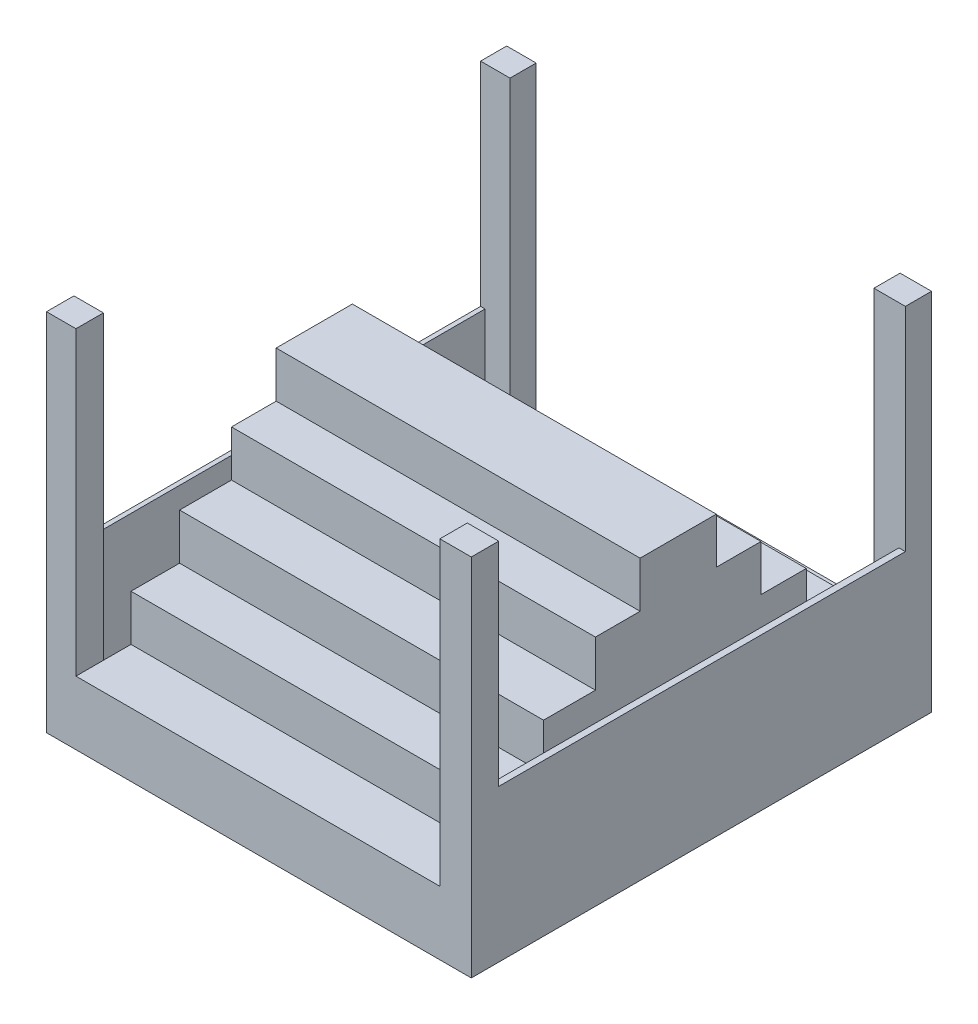
from build123d import *

# Parameters (mm, degrees)
CROQUIS1_W              = 1200
CROQUIS1_H              = 1300
SALIENTE_EXTRUIR1_DEPTH = 30
CROQUIS2_W              = 83.202896363
CROQUIS2_H              = 73.82225968
CROQUIS2_W_2            = 88.769831052
CROQUIS2_H_2            = 77.533549472
SALIENTE_EXTRUIR2_DEPTH = 1000
CROQUIS3_W              = 12.688390301
CROQUIS3_H              = 1148.644190848
CROQUIS3_W_2            = 18.255324991
SALIENTE_EXTRUIR3_DEPTH = 400
CROQUIS4_W              = 1028.027272585
CROQUIS4_H              = 1300
SALIENTE_EXTRUIR4_DEPTH = 150
CROQUIS5_W              = 1028.027272585
CROQUIS5_H              = 1005.759533828
SALIENTE_EXTRUIR5_DEPTH = 130
CROQUIS6_W              = 1028.027272585
CROQUIS6_H              = 742.257958545
SALIENTE_EXTRUIR6_DEPTH = 130
CROQUIS7_W              = 1028.027272585
CROQUIS7_H              = 467.622513883
SALIENTE_EXTRUIR7_DEPTH = 130
CROQUIS8_W              = 1028.027272585
CROQUIS8_H              = 215.254807978
SALIENTE_EXTRUIR8_DEPTH = 130


with BuildPart() as part:
    # Croquis1 → Saliente-Extruir1 (new body)
    with BuildSketch(Plane(origin=(0, 0, 0), x_dir=(1, 0, 0), z_dir=(0, 1, 0))):
        with Locations((600, 650)):
            Rectangle(CROQUIS1_W, CROQUIS1_H)
    extrude(amount=SALIENTE_EXTRUIR1_DEPTH)

    # Croquis2 → Saliente-Extruir2 (add)
    with BuildSketch(Plane(origin=(0, 30, 0), x_dir=(1, 0, 0), z_dir=(0, 1, 0))):
        with Locations((41.601448182, 1263.08887016)):
            Rectangle(CROQUIS2_W, CROQUIS2_H)
        with Locations((1155.615084474, 1263.08887016)):
            Rectangle(CROQUIS2_W_2, CROQUIS2_H)
        with Locations((41.601448182, 38.766774736)):
            Rectangle(CROQUIS2_W, CROQUIS2_H_2)
        with Locations((1155.615084474, 38.766774736)):
            Rectangle(CROQUIS2_W_2, CROQUIS2_H_2)
    extrude(amount=SALIENTE_EXTRUIR2_DEPTH)

    # Croquis3 → Saliente-Extruir3 (add)
    with BuildSketch(Plane(origin=(0, 30, 0), x_dir=(1, 0, 0), z_dir=(0, 1, 0))):
        with Locations((6.344195151, 651.855644896)):
            Rectangle(CROQUIS3_W, CROQUIS3_H)
        with Locations((1190.872337505, 651.855644896)):
            Rectangle(CROQUIS3_W_2, CROQUIS3_H)
    extrude(amount=SALIENTE_EXTRUIR3_DEPTH)

    # Croquis4 → Saliente-Extruir4 (add)
    with BuildSketch(Plane(origin=(0, 30, 0), x_dir=(1, 0, 0), z_dir=(0, 1, 0))):
        with Locations((597.216532656, 650)):
            Rectangle(CROQUIS4_W, CROQUIS4_H)
    extrude(amount=SALIENTE_EXTRUIR4_DEPTH)

    # Croquis5 → Saliente-Extruir5 (add)
    with BuildSketch(Plane(origin=(0, 180, 0), x_dir=(1, 0, 0), z_dir=(0, 1, 0))):
        with Locations((597.216532656, 658.350402034)):
            Rectangle(CROQUIS5_W, CROQUIS5_H)
    extrude(amount=SALIENTE_EXTRUIR5_DEPTH)

    # Croquis6 → Saliente-Extruir6 (add)
    with BuildSketch(Plane(origin=(0, 310, 0), x_dir=(1, 0, 0), z_dir=(0, 1, 0))):
        with Locations((597.216532656, 663.917336723)):
            Rectangle(CROQUIS6_W, CROQUIS6_H)
    extrude(amount=SALIENTE_EXTRUIR6_DEPTH)

    # Croquis7 → Saliente-Extruir7 (add)
    with BuildSketch(Plane(origin=(0, 440, 0), x_dir=(1, 0, 0), z_dir=(0, 1, 0))):
        with Locations((597.216532656, 673.195561204)):
            Rectangle(CROQUIS7_W, CROQUIS7_H)
    extrude(amount=SALIENTE_EXTRUIR7_DEPTH)

    # Croquis8 → Saliente-Extruir8 (add)
    with BuildSketch(Plane(origin=(0, 570, 0), x_dir=(1, 0, 0), z_dir=(0, 1, 0))):
        with Locations((597.216532656, 673.195561205)):
            Rectangle(CROQUIS8_W, CROQUIS8_H)
    extrude(amount=SALIENTE_EXTRUIR8_DEPTH)


solid = part.part
